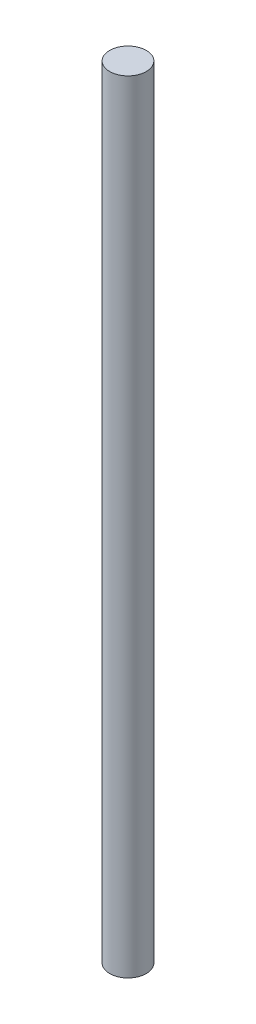
from build123d import *

# Parameters (mm, degrees)
SKETCH1_R           = 2.38125
BOSS_EXTRUDE1_DEPTH = 101.6


with BuildPart() as part:
    # Sketch1 → Boss-Extrude1 (new body)
    with BuildSketch(Plane(origin=(0, 0, 0), x_dir=(1, 0, 0), z_dir=(0, 1, 0))):
        Circle(SKETCH1_R)
    extrude(amount=BOSS_EXTRUDE1_DEPTH)


solid = part.part
